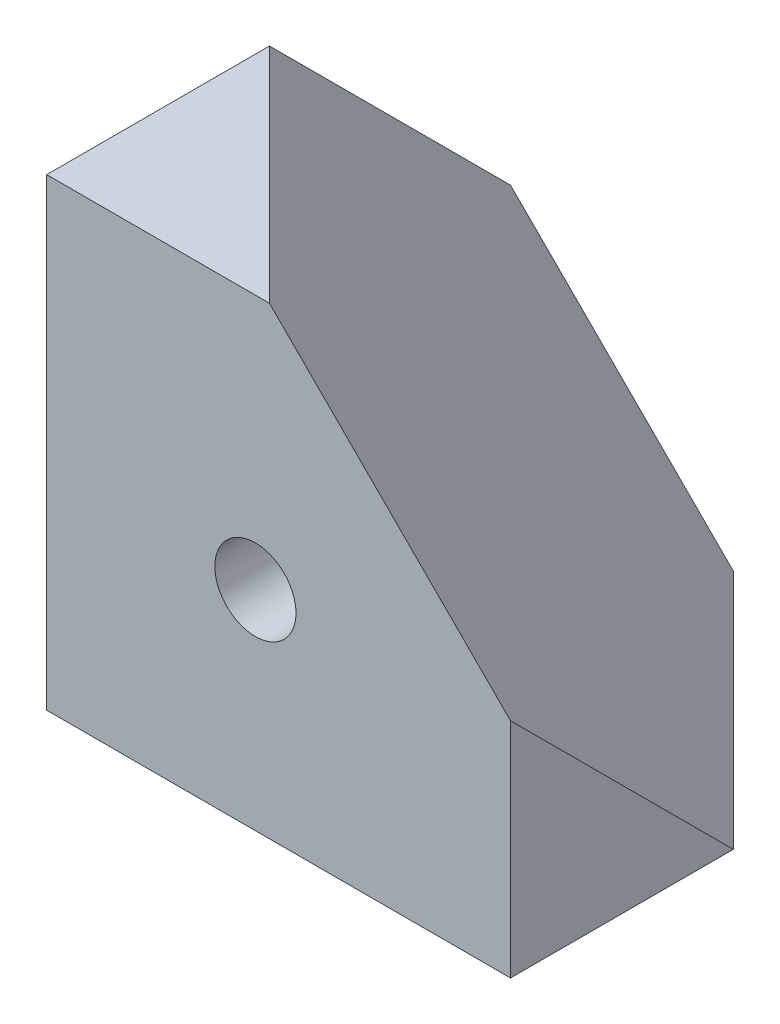
from build123d import *

# Parameters (mm, degrees)
ESQUISSE1_W                  = 20
ESQUISSE1_H                  = 20
BOSS_EXTRU_1_DEPTH           = 20
ENL_V_MAT_EXTRU_1_DEPTH      = 6
ENL_V_MAT_EXTRU_1_DEPTH_BACK = 33.659863237
ESQUISSE2_W                  = 32.659863237
ESQUISSE2_H                  = 28.284271247
ENL_V_MAT_EXTRU_2_DEPTH      = 35.641016151
ENL_V_MAT_EXTRU_2_DEPTH_BACK = 8
ESQUISSE4_R                  = 1.75
ENL_V_MAT_EXTRU_3_DEPTH      = 35.641016151
ENL_V_MAT_EXTRU_3_DEPTH_BACK = 8
ESQUISSE5_R                  = 1.75
ENL_V_MAT_EXTRU_4_DEPTH      = 35.641016151
ENL_V_MAT_EXTRU_4_DEPTH_BACK = 8
ESQUISSE6_R                  = 1.75


with BuildPart() as part:
    # Esquisse1 → Boss.-Extru.1 (new body)
    with BuildSketch(Plane.XY):
        with Locations((10, 10)):
            Rectangle(ESQUISSE1_W, ESQUISSE1_H)
    extrude(amount=BOSS_EXTRU_1_DEPTH)

    # Esquisse2 → Enlèv. mat.-Extru.1 (cut, two sides: drawn at the far end of the back side and taken through both)
    with BuildSketch(Plane(origin=(6.666666667, 6.666666667, -6.666666667), x_dir=(0.8164965809277261, -0.408248290463863, 0.40824829046386313), z_dir=(-0.5773502691896258, -0.5773502691896258, 0.5773502691896258)).offset(-ENL_V_MAT_EXTRU_1_DEPTH_BACK)):
        with Locations((8.164965809, 14.142135624)):
            Rectangle(ESQUISSE2_W, ESQUISSE2_H)
    extrude(amount=ENL_V_MAT_EXTRU_1_DEPTH + ENL_V_MAT_EXTRU_1_DEPTH_BACK, mode=Mode.SUBTRACT)

    # Esquisse4 → Enlèv. mat.-Extru.2 (cut, two sides: drawn at the far end of the back side and taken through both)
    with BuildSketch(Plane.XZ.offset(-ENL_V_MAT_EXTRU_2_DEPTH_BACK)):
        with Locations((9, 11)):
            Circle(ESQUISSE4_R)
    extrude(amount=ENL_V_MAT_EXTRU_2_DEPTH + ENL_V_MAT_EXTRU_2_DEPTH_BACK, mode=Mode.SUBTRACT)

    # Esquisse5 → Enlèv. mat.-Extru.3 (cut, two sides: drawn at the far end of the back side and taken through both)
    with BuildSketch(Plane.XY.offset(20).offset(-ENL_V_MAT_EXTRU_3_DEPTH_BACK)):
        with Locations((9, 9)):
            Circle(ESQUISSE5_R)
    extrude(amount=ENL_V_MAT_EXTRU_3_DEPTH + ENL_V_MAT_EXTRU_3_DEPTH_BACK, mode=Mode.SUBTRACT)

    # Esquisse6 → Enlèv. mat.-Extru.4 (cut, two sides: drawn at the far end of the back side and taken through both)
    with BuildSketch(Plane.ZY.offset(-ENL_V_MAT_EXTRU_4_DEPTH_BACK)):
        with Locations((11, 9)):
            Circle(ESQUISSE6_R)
    extrude(amount=ENL_V_MAT_EXTRU_4_DEPTH + ENL_V_MAT_EXTRU_4_DEPTH_BACK, mode=Mode.SUBTRACT)


solid = part.part
